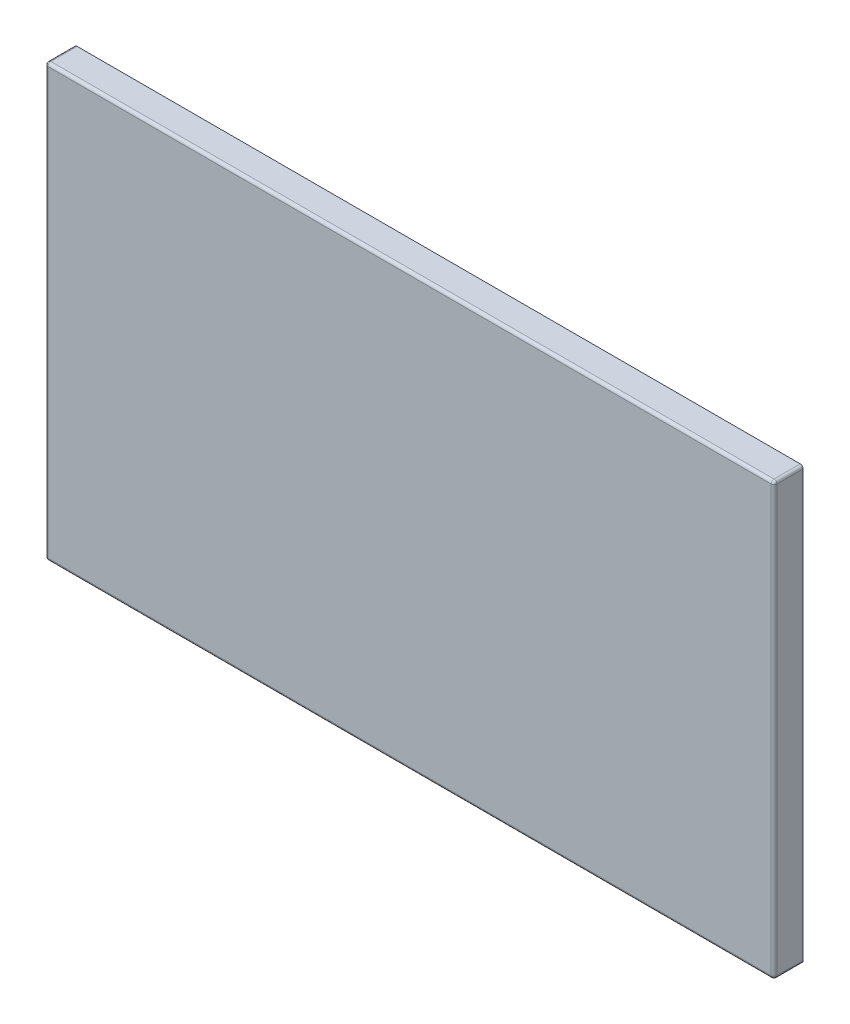
from build123d import *

# Parameters (mm, degrees)
SKETCH1_W           = 2500
SKETCH1_H           = 1480
BOSS_EXTRUDE1_DEPTH = 100
SHELL1_T            = -20
FILLET1_R           = 10


with BuildPart() as part:
    # Sketch1 → Boss-Extrude1 (new body)
    with BuildSketch(Plane.XY):
        with Locations((1250, 740)):
            Rectangle(SKETCH1_W, SKETCH1_H)
    extrude(amount=BOSS_EXTRUDE1_DEPTH)

    # Shell1
    shell1_openings = [part.faces().sort_by_distance(p)[0] for p in [
        (1250, 740, 0),
    ]]
    offset(amount=SHELL1_T, openings=shell1_openings, kind=Kind.INTERSECTION)

    # Fillet1
    fillet1_edges = [part.edges().sort_by_distance(p)[0] for p in [
        (2500, 740, 100),
        (1250, 1480, 100),
        (0, 740, 100),
        (0, 1480, 50),
        (2500, 1480, 50),
        (2500, 0, 50),
        (0, 0, 50),
        (1250, 0, 100),
    ]]
    fillet(fillet1_edges, radius=FILLET1_R)


solid = part.part
